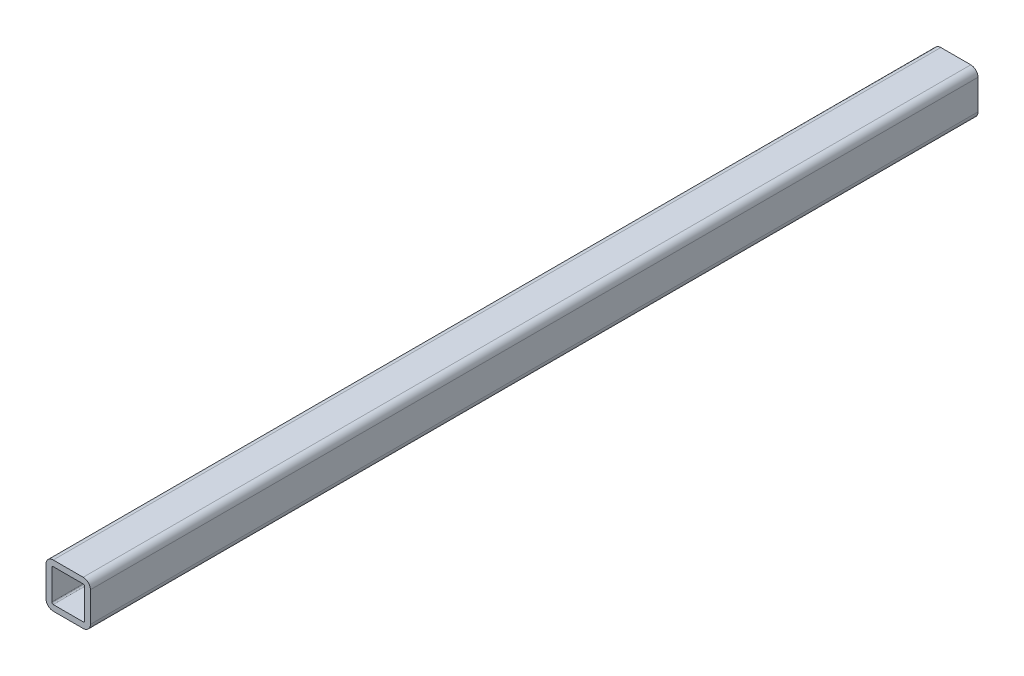
from build123d import *

# Parameters (mm, degrees)
BOSS_EXTRUDE1_DEPTH = 127


with BuildPart() as part:
    # Sketch4 → Boss-Extrude1 (new body, symmetric)
    with BuildSketch(Plane.XY):
        with BuildLine():
            Line((6.35, -4.28625), (6.35, 4.28625))
            ThreePointArc((6.35, 4.28625), (5.74554162, 5.74554162), (4.28625, 6.35))
            Line((4.28625, 6.35), (-4.28625, 6.35))
            ThreePointArc((-4.28625, 6.35), (-5.74554162, 5.74554162), (-6.35, 4.28625))
            Line((-6.35, 4.28625), (-6.35, -4.28625))
            ThreePointArc((-6.35, -4.28625), (-5.74554162, -5.74554162), (-4.28625, -6.35))
            Line((-4.28625, -6.35), (4.28625, -6.35))
            ThreePointArc((4.28625, -6.35), (5.74554162, -5.74554162), (6.35, -4.28625))
        make_face()
        with BuildLine():
            Line((4.699, 4.28625), (4.699, -4.28625))
            ThreePointArc((4.699, -4.28625), (4.578108324, -4.578108324), (4.28625, -4.699))
            Line((4.28625, -4.699), (-4.28625, -4.699))
            ThreePointArc((-4.28625, -4.699), (-4.578108324, -4.578108324), (-4.699, -4.28625))
            Line((-4.699, -4.28625), (-4.699, 4.28625))
            ThreePointArc((-4.699, 4.28625), (-4.578108324, 4.578108324), (-4.28625, 4.699))
            Line((-4.28625, 4.699), (4.28625, 4.699))
            ThreePointArc((4.28625, 4.699), (4.578108324, 4.578108324), (4.699, 4.28625))
        make_face(mode=Mode.SUBTRACT)
    extrude(amount=BOSS_EXTRUDE1_DEPTH, both=True)


solid = part.part
